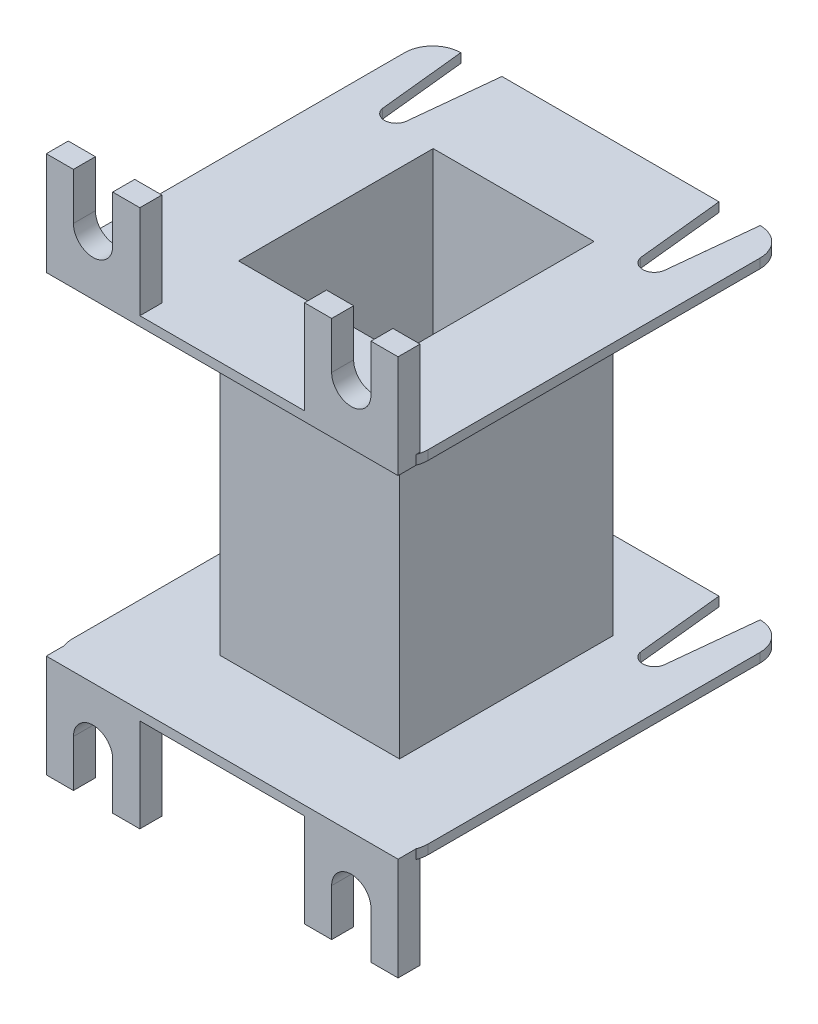
from build123d import *

# Parameters (mm, degrees)
SKETCH1_W           = 17.2
SKETCH1_H           = 20.8
BOSS_EXTRUDE1_DEPTH = 1
SKETCH2_W           = 19.2
SKETCH2_H           = 22.8
SKETCH2_W_2         = 17.2
SKETCH2_H_2         = 20.8
BOSS_EXTRUDE2_DEPTH = 35.5
SKETCH3_W           = 17.2
SKETCH3_H           = 20.8
BOSS_EXTRUDE3_DEPTH = 1
CUT_EXTRUDE1_DEPTH  = 38.5
BOSS_EXTRUDE4_DEPTH = 11
SKETCH8_W           = 10
SKETCH8_H           = 2.35
BOSS_EXTRUDE5_DEPTH = 11
CUT_EXTRUDE2_DEPTH  = 42.5


with BuildPart() as part:
    # Sketch1 → Boss-Extrude1 (new body)
    with BuildSketch(Plane(origin=(0, 0, 0), x_dir=(1, 0, 0), z_dir=(0, 1, 0))):
        with BuildLine():
            Line((-16, -20.75), (16, -20.75))
            ThreePointArc((16, -20.75), (18.121320344, -19.871320344), (19, -17.75))
            Line((19, -17.75), (19, 17.75))
            ThreePointArc((19, 17.75), (18.121320344, 19.871320344), (16, 20.75))
            Line((16, 20.75), (-16, 20.75))
            ThreePointArc((-16, 20.75), (-18.121320344, 19.871320344), (-19, 17.75))
            Line((-19, 17.75), (-19, -17.75))
            ThreePointArc((-19, -17.75), (-18.121320344, -19.871320344), (-16, -20.75))
        make_face()
        Rectangle(SKETCH1_W, SKETCH1_H, mode=Mode.SUBTRACT)
    extrude(amount=BOSS_EXTRUDE1_DEPTH)

    # Sketch2 → Boss-Extrude2 (add)
    with BuildSketch(Plane(origin=(0, 1, 0), x_dir=(1, 0, 0), z_dir=(0, 1, 0))):
        Rectangle(SKETCH2_W, SKETCH2_H)
        Rectangle(SKETCH2_W_2, SKETCH2_H_2, mode=Mode.SUBTRACT)
    extrude(amount=BOSS_EXTRUDE2_DEPTH)

    # Sketch3 → Boss-Extrude3 (add)
    with BuildSketch(Plane(origin=(0, 36.5, 0), x_dir=(1, 0, 0), z_dir=(0, 1, 0))):
        with BuildLine():
            Line((-16, -20.75), (16, -20.75))
            ThreePointArc((16, -20.75), (18.121320344, -19.871320344), (19, -17.75))
            Line((19, -17.75), (19, 17.75))
            ThreePointArc((19, 17.75), (18.121320344, 19.871320344), (16, 20.75))
            Line((16, 20.75), (-16, 20.75))
            ThreePointArc((-16, 20.75), (-18.121320344, 19.871320344), (-19, 17.75))
            Line((-19, 17.75), (-19, -17.75))
            ThreePointArc((-19, -17.75), (-18.121320344, -19.871320344), (-16, -20.75))
        make_face()
        Rectangle(SKETCH3_W, SKETCH3_H, mode=Mode.SUBTRACT)
    extrude(amount=BOSS_EXTRUDE3_DEPTH)

    # Sketch4 → Cut-Extrude1 (cut, through all)
    with BuildSketch(Plane(origin=(0, 37.5, 0), x_dir=(-1, 0, 0), z_dir=(0, 1, 0))):
        with BuildLine():
            Line((11.6, -20.75), (12.572602238, -11.413367935))
            ThreePointArc((12.572602238, -11.413367935), (13.8, -10.4), (15.027397762, -11.413367935))
            Line((15.027397762, -11.413367935), (16, -20.75))
            Line((16, -20.75), (11.6, -20.75))
        make_face()
        with BuildLine():
            Line((-11.6, -20.75), (-12.572602238, -11.413367935))
            ThreePointArc((-12.572602238, -11.413367935), (-13.8, -10.4), (-15.027397762, -11.413367935))
            Line((-15.027397762, -11.413367935), (-16, -20.75))
            Line((-16, -20.75), (-11.6, -20.75))
        make_face()
    extrude(amount=-CUT_EXTRUDE1_DEPTH, mode=Mode.SUBTRACT)

    # Sketch6 → Boss-Extrude4 (add)
    with BuildSketch(Plane.XZ.offset(-36.5)):
        Polygon((-13.8, 20.75), (-18.8, 20.75), (-18.8, 18.4), (-8.8, 18.4), (-8.8, 20.75), align=None)
        Polygon((8.8, 18.4), (8.8, 20.75), (13.8, 20.75), (18.8, 20.75), (18.8, 18.4), align=None)
    extrude(amount=-BOSS_EXTRUDE4_DEPTH)

    # Sketch8 → Boss-Extrude5 (add)
    with BuildSketch(Plane(origin=(0, 1, 0), x_dir=(1, 0, 0), z_dir=(0, 1, 0))):
        with Locations((-13.8, -19.575)):
            Rectangle(SKETCH8_W, SKETCH8_H)
        with Locations((13.8, -19.575)):
            Rectangle(SKETCH8_W, SKETCH8_H)
    extrude(amount=-BOSS_EXTRUDE5_DEPTH)

    # Sketch9 → Cut-Extrude2 (cut, through all)
    with BuildSketch(Plane.XY.offset(20.75)):
        with BuildLine():
            Line((-15.9, -4.996046188), (-15.9, -10))
            Line((-15.9, -10), (-11.7, -10))
            Line((-11.7, -10), (-11.7, -4.996046188))
            ThreePointArc((-11.7, -4.996046188), (-13.8, -2.896046188), (-15.9, -4.996046188))
        make_face()
        with BuildLine():
            Line((15.9, -10), (11.7, -10))
            Line((11.7, -10), (11.7, -4.996046188))
            ThreePointArc((11.7, -4.996046188), (13.8, -2.896046188), (15.9, -4.996046188))
            Line((15.9, -4.996046188), (15.9, -10))
        make_face()
        with BuildLine():
            Line((15.9, 47.5), (11.7, 47.5))
            Line((11.7, 47.5), (11.7, 42.496046188))
            ThreePointArc((11.7, 42.496046188), (13.8, 40.396046188), (15.9, 42.496046188))
            Line((15.9, 42.496046188), (15.9, 47.5))
        make_face()
        with BuildLine():
            Line((-15.9, 47.5), (-11.7, 47.5))
            Line((-11.7, 47.5), (-11.7, 42.496046188))
            ThreePointArc((-11.7, 42.496046188), (-13.8, 40.396046188), (-15.9, 42.496046188))
            Line((-15.9, 42.496046188), (-15.9, 47.5))
        make_face()
    extrude(amount=-CUT_EXTRUDE2_DEPTH, mode=Mode.SUBTRACT)


solid = part.part
